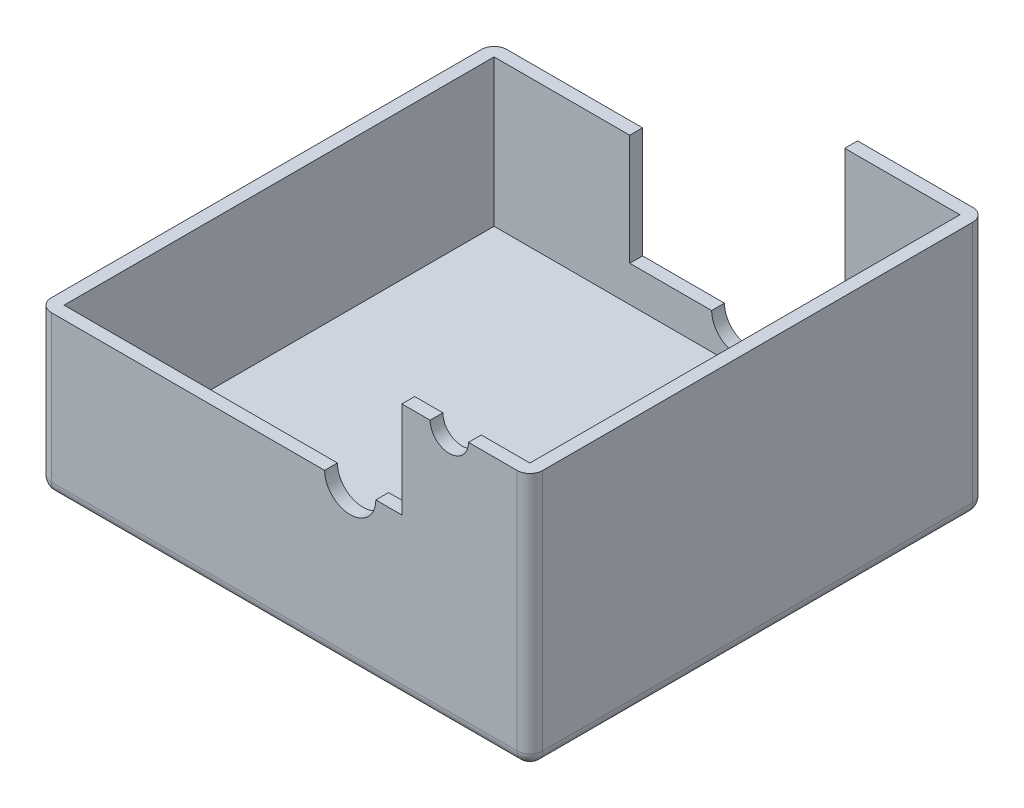
from build123d import *

# Parameters (mm, degrees)
SKETCH1_W           = 96
SKETCH1_H           = 89
BOSS_EXTRUDE1_DEPTH = 72.5
SKETCH3_W           = 91
SKETCH3_H           = 84
CUT_EXTRUDE1_DEPTH  = 70
CUT_EXTRUDE5_DEPTH  = 90
SKETCH7_R           = 3.75
SKETCH7_R_2         = 5
CUT_EXTRUDE6_DEPTH  = 2.5
SKETCH8_W           = 42
SKETCH8_H           = 21.66
CUT_EXTRUDE7_DEPTH  = 2.5
CUT_EXTRUDE8_DEPTH  = 2.5
FILLET1_R           = 2.5


with BuildPart() as part:
    # Sketch1 → Boss-Extrude1 (new body)
    with BuildSketch(Plane(origin=(0, 0, 0), x_dir=(1, 0, 0), z_dir=(0, 1, 0))):
        with Locations((48, -44.5)):
            Rectangle(SKETCH1_W, SKETCH1_H)
    extrude(amount=BOSS_EXTRUDE1_DEPTH)

    # Sketch3 → Cut-Extrude1 (cut)
    with BuildSketch(Plane(origin=(0, 72.5, 0), x_dir=(1, 0, 0), z_dir=(0, 1, 0))):
        with Locations((48, -44.5)):
            Rectangle(SKETCH3_W, SKETCH3_H)
    extrude(amount=-CUT_EXTRUDE1_DEPTH, mode=Mode.SUBTRACT)

    # Sketch5 → Cut-Extrude5 (cut, through all)
    with BuildSketch(Plane.XY.offset(89)):
        Polygon((0, 31.16), (0, 72.5), (96, 72.5), (96, 49.95), (80.25, 49.95), (71, 49.95), (71, 31.16), align=None)
    extrude(amount=-CUT_EXTRUDE5_DEPTH, mode=Mode.SUBTRACT)

    # Sketch7 → Cut-Extrude6 (cut)
    with BuildSketch(Plane.XY.offset(89)):
        with Locations((80.25, 49.95)):
            Circle(SKETCH7_R)
        with Locations((60.9, 31.16)):
            Circle(SKETCH7_R_2)
    extrude(amount=-CUT_EXTRUDE6_DEPTH, mode=Mode.SUBTRACT)

    # Sketch8 → Cut-Extrude7 (cut)
    with BuildSketch(Plane(origin=(0, 0, 0), x_dir=(-1, 0, 0), z_dir=(0, 0, -1))):
        with Locations((-50, 20.33)):
            Rectangle(SKETCH8_W, SKETCH8_H)
    extrude(amount=-CUT_EXTRUDE7_DEPTH, mode=Mode.SUBTRACT)

    # Sketch9 → Cut-Extrude8 (cut)
    with BuildSketch(Plane(origin=(0, 0, 0), x_dir=(-1, 0, 0), z_dir=(0, 0, -1))):
        with BuildLine():
            Line((-55, 9.5), (-45, 9.5))
            ThreePointArc((-45, 9.5), (-50, 4.5), (-55, 9.5))
        make_face()
    extrude(amount=-CUT_EXTRUDE8_DEPTH, mode=Mode.SUBTRACT)

    # Fillet1
    fillet1_edges = [part.edges().sort_by_distance(p)[0] for p in [
        (0, 15.58, 0),
        (96, 24.975, 0),
        (96, 24.975, 89),
        (0, 15.58, 89),
        (48, 0, 0),
        (96, 0, 44.5),
        (48, 0, 89),
        (0, 0, 44.5),
    ]]
    fillet(fillet1_edges, radius=FILLET1_R)


solid = part.part
